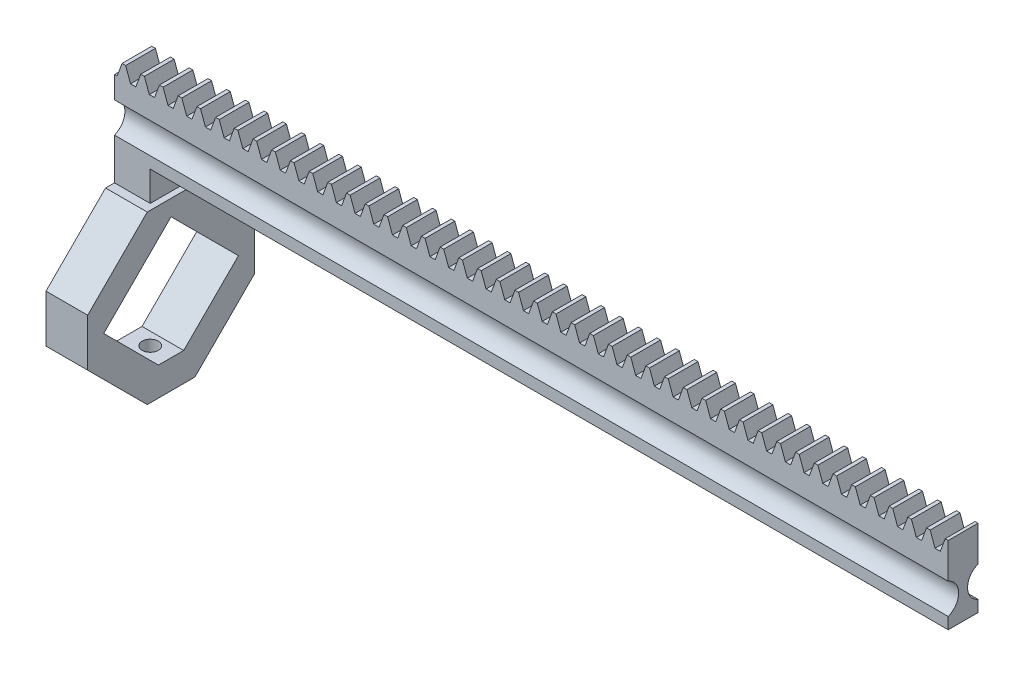
from build123d import *

# Parameters (mm, degrees)
BLANKSKE_W              = 140
BLANKSKE_H              = 13
BLANK_DEPTH             = 5
TOOTHCUTSIM_DEPTH       = 141.691151108
TEETHCUTS_COUNT         = 45
TEETHCUTS_PITCH         = 3.14159265
SKETCH1_R               = 2.75
CUT_EXTRUDE2_DEPTH      = 141.691151108
CUT_EXTRUDE2_DEPTH_BACK = 10
SKETCH15_W              = 6
SKETCH15_H              = 5
BOSS_EXTRUDE4_DEPTH     = 5
SKETCH16_W              = 28
SKETCH16_H              = 28
BOSS_EXTRUDE5_DEPTH     = 7
CUT_EXTRUDE6_DEPTH      = 10
CHAMFER4_SIZE           = 3
CHAMFER5_SIZE           = 10
SKETCH18_R              = 1.35
CUT_EXTRUDE7_DEPTH      = 10


with BuildPart() as part:
    # BlankSke → Blank (new body)
    with BuildSketch(Plane.XY):
        with Locations((70, 6.5)):
            Rectangle(BLANKSKE_W, BLANKSKE_H)
    extrude(amount=-BLANK_DEPTH)

    # TooCutSkeSim → ToothCutSim (cut, through all)
    with BuildSketch(Plane.XY):
        Polygon((0.44443537, 10.75), (-0.44443537, 10.75), (-1.272613241, 13.0254), (1.272613241, 13.0254), align=None)
    toothcutsim = extrude(amount=-TOOTHCUTSIM_DEPTH, mode=Mode.SUBTRACT)

    # TeethCuts: ToothCutSim ×45
    with Locations(*[(i * TEETHCUTS_PITCH, 0, 0) for i in range(1, TEETHCUTS_COUNT)]):
        add(toothcutsim, mode=Mode.SUBTRACT)

    # Sketch1 → Cut-Extrude2 (cut, two sides)
    with BuildSketch(Plane(origin=(0, 0, 0), x_dir=(0, 0, -1), z_dir=(1, 0, 0))) as cut_extrude2_sk:
        with Locations((6, 4.5)):
            Circle(SKETCH1_R)
        with Locations((-1, 4.5)):
            Circle(SKETCH1_R)
    extrude(amount=CUT_EXTRUDE2_DEPTH, mode=Mode.SUBTRACT)
    extrude(cut_extrude2_sk.sketch, amount=-CUT_EXTRUDE2_DEPTH_BACK, mode=Mode.SUBTRACT)

    # Sketch15 → Boss-Extrude4 (add)
    with BuildSketch(Plane.XZ):
        with Locations((3, -2.5)):
            Rectangle(SKETCH15_W, SKETCH15_H)
    extrude(amount=BOSS_EXTRUDE4_DEPTH)

    # Sketch16 → Boss-Extrude5 (add)
    with BuildSketch(Plane.ZY):
        with Locations((-2.5, -19)):
            Rectangle(SKETCH16_W, SKETCH16_H)
    extrude(amount=-BOSS_EXTRUDE5_DEPTH)

    # Sketch17 → Cut-Extrude6 (cut)
    with BuildSketch(Plane.ZY):
        Polygon((-13.813708499, -19), (-2.5, -7.686291501), (8.813708499, -19), (-2.5, -30.313708499), align=None)
    extrude(amount=-CUT_EXTRUDE6_DEPTH, mode=Mode.SUBTRACT)

    # Chamfer4
    chamfer4_edges = [part.edges().sort_by_distance(p)[0] for p in [
        (3.5, -30.313708499, -2.5),
    ]]
    chamfer(chamfer4_edges, length=CHAMFER4_SIZE)

    # Chamfer5
    chamfer5_edges = [part.edges().sort_by_distance(p)[0] for p in [
        (3.5, -5, 11.5),
        (3.5, -33, 11.5),
        (3.5, -33, -16.5),
        (3.5, -5, -16.5),
    ]]
    chamfer(chamfer5_edges, length=CHAMFER5_SIZE)

    # Sketch18 → Cut-Extrude7 (cut)
    with BuildSketch(Plane.XZ.offset(33)):
        with Locations(Location((3.5, -2.5, 0), (0, 0, 270))):
            Circle(SKETCH18_R)
    extrude(amount=-CUT_EXTRUDE7_DEPTH, mode=Mode.SUBTRACT)


solid = part.part
